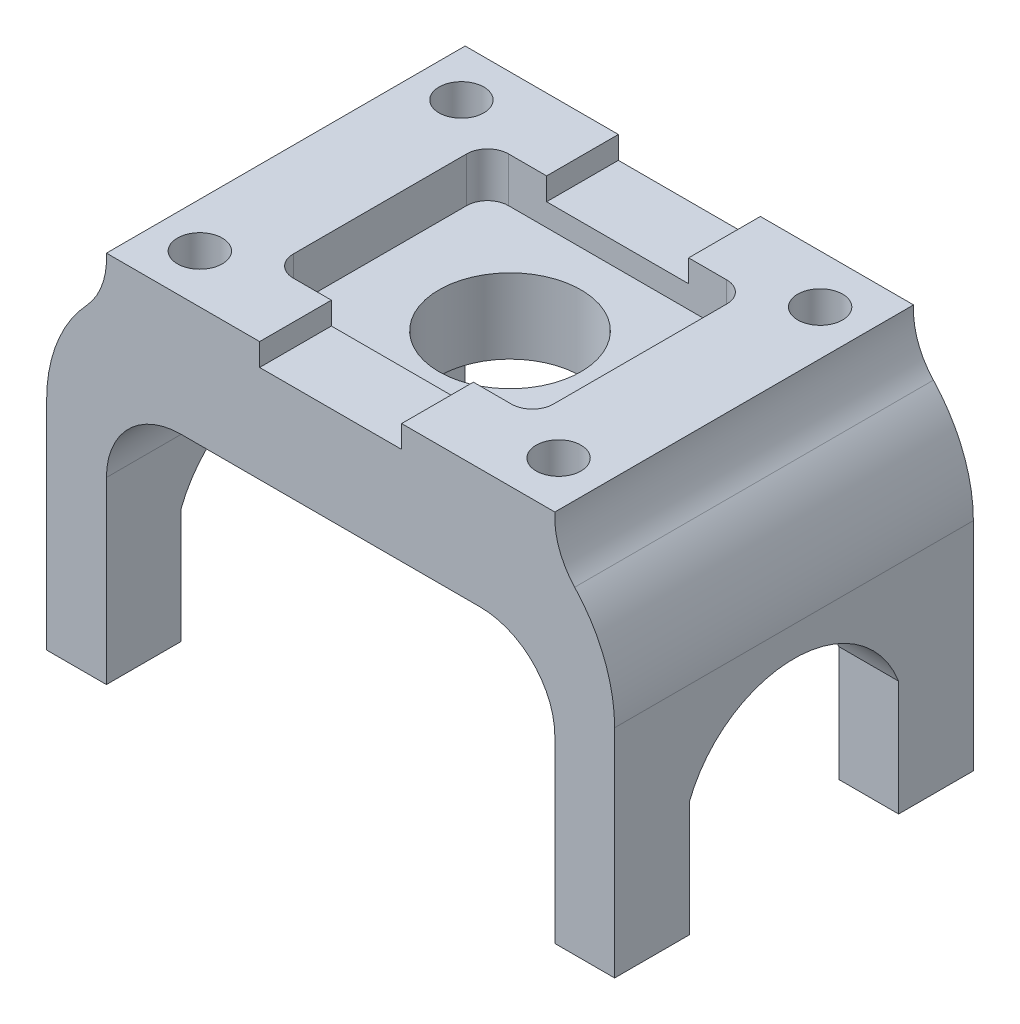
from build123d import *

# Parameters (mm, degrees)
EXTRUDE1_DEPTH          = 60.96
CUT_EXTRUDE1_DEPTH      = 50.893408892
CUT_EXTRUDE1_DEPTH_BACK = 47.626591108
SKETCH5_W               = 44.196
SKETCH5_H               = 36.576
CUT_EXTRUDE3_DEPTH      = 3.81
CUT_EXTRUDE3_DEPTH_BACK = 3.81
FILLET1_R               = 3.556
FILLET2_R               = 3.556
SKETCH6_R               = 12.065
CUT_EXTRUDE4_DEPTH      = 56.88
SKETCH7_R               = 3.81
CUT_EXTRUDE5_DEPTH      = 64.5
LPATTERN1_COUNT         = 2
LPATTERN1_PITCH         = 60.96
LPATTERN1_COUNT_DIR2    = 2
LPATTERN1_PITCH_DIR2    = 44.45


with BuildPart() as part:
    # Sketch1 → Extrude1 (new body)
    with BuildSketch(Plane.XY):
        with BuildLine():
            Line((-4.519970737, -20.32), (7.786788522, -20.32))
            Line((7.786788522, -20.32), (27.033408892, -20.32))
            ThreePointArc((27.033408892, -20.32), (36.013665013, -24.039743879), (39.733408892, -33.02))
            Line((39.733408892, -33.02), (39.733408892, -63.5))
            Line((39.733408892, -63.5), (49.893408892, -63.5))
            Line((49.893408892, -63.5), (49.893408892, -26.67))
            ThreePointArc((49.893408892, -26.67), (48.135622025, -17.385294394), (43.105553917, -9.385670173))
            ThreePointArc((43.105553917, -9.385670173), (40.459641097, -5.037692796), (39.733408892, 0))
            Line((39.733408892, 0), (13.698408892, 0))
            Line((13.698408892, 0), (13.698408892, -3.81))
            Line((13.698408892, -3.81), (-10.431591108, -3.81))
            Line((-10.431591108, -3.81), (-10.431591108, 0))
            Line((-10.431591108, 0), (-36.466591108, 0))
            ThreePointArc((-36.466591108, 0), (-37.192823312, -5.037692796), (-39.838736133, -9.385670173))
            ThreePointArc((-39.838736133, -9.385670173), (-44.868804241, -17.385294394), (-46.626591108, -26.67))
            Line((-46.626591108, -26.67), (-46.626591108, -63.5))
            Line((-46.626591108, -63.5), (-36.466591108, -63.5))
            Line((-36.466591108, -63.5), (-36.466591108, -33.02))
            ThreePointArc((-36.466591108, -33.02), (-32.746847229, -24.039743879), (-23.766591108, -20.32))
            Line((-23.766591108, -20.32), (-4.519970737, -20.32))
        make_face()
    extrude(amount=-EXTRUDE1_DEPTH)

    # Sketch4 → Cut-Extrude1 (cut, two sides)
    with BuildSketch(Plane(origin=(0, 0, 0), x_dir=(0, 0, -1), z_dir=(1, 0, 0))) as cut_extrude1_sk:
        with BuildLine():
            Line((12.7, -233.015235636), (12.7, -63.5))
            Line((12.7, -63.5), (12.7, -43.942))
            ThreePointArc((12.7, -43.942), (30.48, -31.731159305), (48.26, -43.942))
            Line((48.26, -43.942), (48.26, -63.5))
            Line((48.26, -63.5), (48.26, -233.015235636))
            Line((48.26, -233.015235636), (48.26, -572.045706908))
            Line((48.26, -572.045706908), (12.7, -572.045706908))
            Line((12.7, -572.045706908), (12.7, -233.015235636))
        make_face()
    extrude(amount=CUT_EXTRUDE1_DEPTH, mode=Mode.SUBTRACT)
    extrude(cut_extrude1_sk.sketch, amount=-CUT_EXTRUDE1_DEPTH_BACK, mode=Mode.SUBTRACT)

    # Sketch5 → Cut-Extrude3 (cut, two sides)
    with BuildSketch(Plane(origin=(0, -3.81, 0), x_dir=(-1, 0, 0), z_dir=(0, 1, 0))) as cut_extrude3_sk:
        with Locations((-1.633408892, -30.48)):
            Rectangle(SKETCH5_W, SKETCH5_H)
    extrude(amount=CUT_EXTRUDE3_DEPTH, mode=Mode.SUBTRACT)
    extrude(cut_extrude3_sk.sketch, amount=-CUT_EXTRUDE3_DEPTH_BACK, mode=Mode.SUBTRACT)

    # Fillet1
    fillet1_edges = [part.edges().sort_by_distance(p)[0] for p in [
        (23.731408892, -3.81, -12.192),
    ]]
    fillet(fillet1_edges, radius=FILLET1_R)

    # Fillet2
    fillet2_edges = [part.edges().sort_by_distance(p)[0] for p in [
        (23.731408892, -3.81, -48.768),
        (-20.464591108, -3.81, -12.192),
        (-20.464591108, -3.81, -48.768),
    ]]
    fillet(fillet2_edges, radius=FILLET2_R)

    # Sketch6 → Cut-Extrude4 (cut, through all)
    with BuildSketch(Plane(origin=(0, -7.62, 0), x_dir=(-1, 0, 0), z_dir=(0, 1, 0))):
        with Locations((-1.633408892, -30.48)):
            Circle(SKETCH6_R)
    extrude(amount=-CUT_EXTRUDE4_DEPTH, mode=Mode.SUBTRACT)

    # Sketch7 → Cut-Extrude5 (cut, through all)
    with BuildSketch(Plane(origin=(0, 0, 0), x_dir=(-1, 0, 0), z_dir=(0, 1, 0))):
        with Locations((-32.113408892, -8.255)):
            Circle(SKETCH7_R)
    cut_extrude5 = extrude(amount=-CUT_EXTRUDE5_DEPTH, mode=Mode.SUBTRACT)

    # LPattern1: Cut-Extrude5 2 × 2
    with Locations(*[(-i * LPATTERN1_PITCH, 0, -j * LPATTERN1_PITCH_DIR2) for i in range(LPATTERN1_COUNT) for j in range(LPATTERN1_COUNT_DIR2) if (i, j) != (0, 0)]):
        add(cut_extrude5, mode=Mode.SUBTRACT)


solid = part.part
